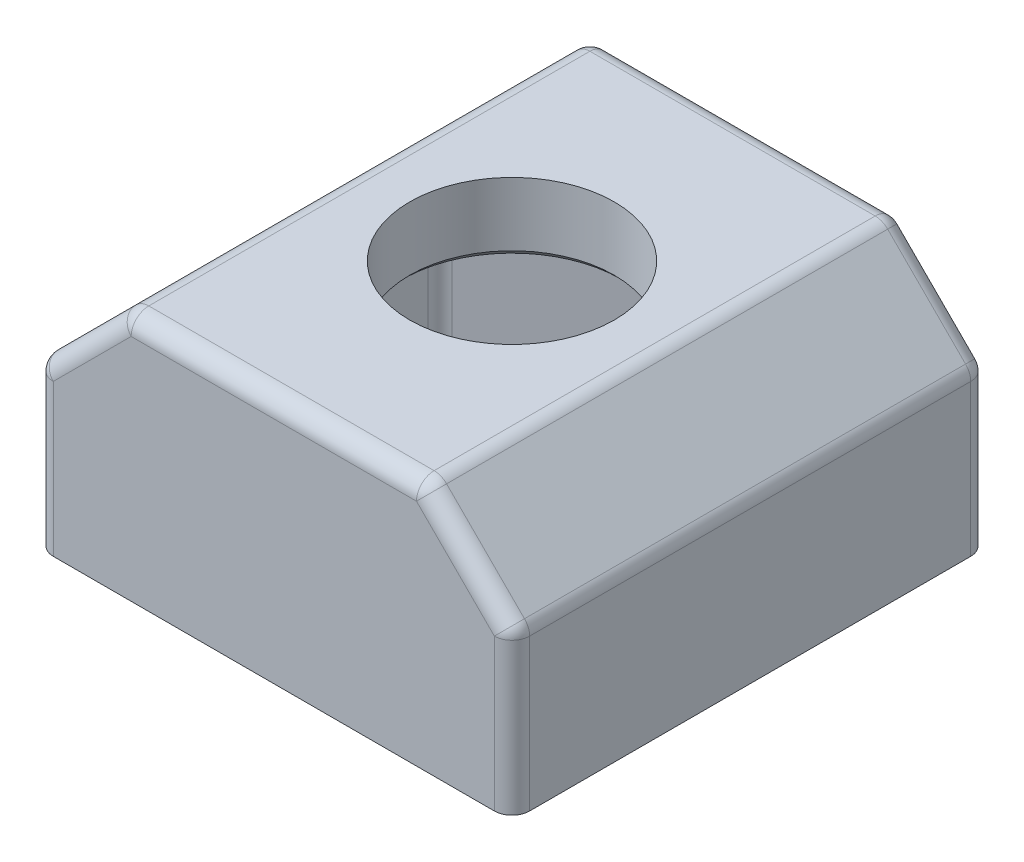
from build123d import *

# Parameters (mm, degrees)
SKETCH1_W           = 13.5
SKETCH1_H           = 13.5
BOSS_EXTRUDE1_DEPTH = 5
SKETCH3_W           = 13.5
SKETCH3_H           = 13.5
BOSS_EXTRUDE2_DEPTH = 2
CHAMFER1_SIZE       = 2.5
FILLET2_R           = 0.5
FILLET1_R           = 0.5
CUT_EXTRUDE1_REACH  = 4
SKETCH4_R           = 2.9
CHAMFER2_SIZE       = 0.2


with BuildPart() as part:
    # Sketch1 → Boss-Extrude1 (new body)
    with BuildSketch(Plane(origin=(0, 0, 0), x_dir=(1, 0, 0), z_dir=(0, 1, 0))):
        Rectangle(SKETCH1_W, SKETCH1_H)
        Polygon((0, -5.715767665), (4.95, -2.857883832), (4.95, 2.857883832), (0, 5.715767665), (-4.95, 2.857883832), (-4.95, -2.857883832), align=None, mode=Mode.SUBTRACT)
    extrude(amount=BOSS_EXTRUDE1_DEPTH)

    # Sketch3 → Boss-Extrude2 (add)
    with BuildSketch(Plane(origin=(0, 5, 0), x_dir=(1, 0, 0), z_dir=(0, 1, 0))):
        Rectangle(SKETCH3_W, SKETCH3_H)
    extrude(amount=BOSS_EXTRUDE2_DEPTH)

    # Chamfer1
    chamfer1_edges = [part.edges().sort_by_distance(p)[0] for p in [
        (-6.75, 7, 0),
        (6.75, 7, 0),
    ]]
    chamfer(chamfer1_edges, length=CHAMFER1_SIZE)

    # Fillet2
    fillet2_edges = [part.edges().sort_by_distance(p)[0] for p in [
        (-4.95, 2.5, 2.857883832),
        (0, 2.5, 5.715767665),
        (4.95, 2.5, 2.857883832),
        (4.95, 2.5, -2.857883832),
        (0, 2.5, -5.715767665),
        (-4.95, 2.5, -2.857883832),
    ]]
    fillet(fillet2_edges, radius=FILLET2_R)

    # Fillet1
    fillet1_edges = [part.edges().sort_by_distance(p)[0] for p in [
        (0, 7, 6.75),
        (0, 7, -6.75),
        (-4.25, 7, 0),
        (4.25, 7, 0),
        (-6.75, 2.25, -6.75),
        (6.75, 2.25, -6.75),
        (-5.5, 5.75, -6.75),
        (5.5, 5.75, -6.75),
        (6.75, 2.25, 6.75),
        (6.75, 4.5, 0),
        (-6.75, 2.25, 6.75),
        (-5.5, 5.75, 6.75),
        (5.5, 5.75, 6.75),
        (-6.75, 4.5, 0),
    ]]
    fillet(fillet1_edges, radius=FILLET1_R)

    # Sketch4 → Cut-Extrude1 (cut, up to next)
    with BuildSketch(Plane.XZ.offset(-5), mode=Mode.PRIVATE) as cut_extrude1_sk1:
        Circle(SKETCH4_R)
    cut_extrude1_tool1 = extrude(cut_extrude1_sk1.sketch, amount=-CUT_EXTRUDE1_REACH, mode=Mode.PRIVATE) & part.part
    add(cut_extrude1_tool1.solids().sort_by_distance((0, 5, 0))[0], mode=Mode.SUBTRACT)

    # Chamfer2
    chamfer2_edges = [part.edges().sort_by_distance(p)[0] for p in [
        (-2.9, 5, 0),
    ]]
    chamfer(chamfer2_edges, length=CHAMFER2_SIZE)


solid = part.part
